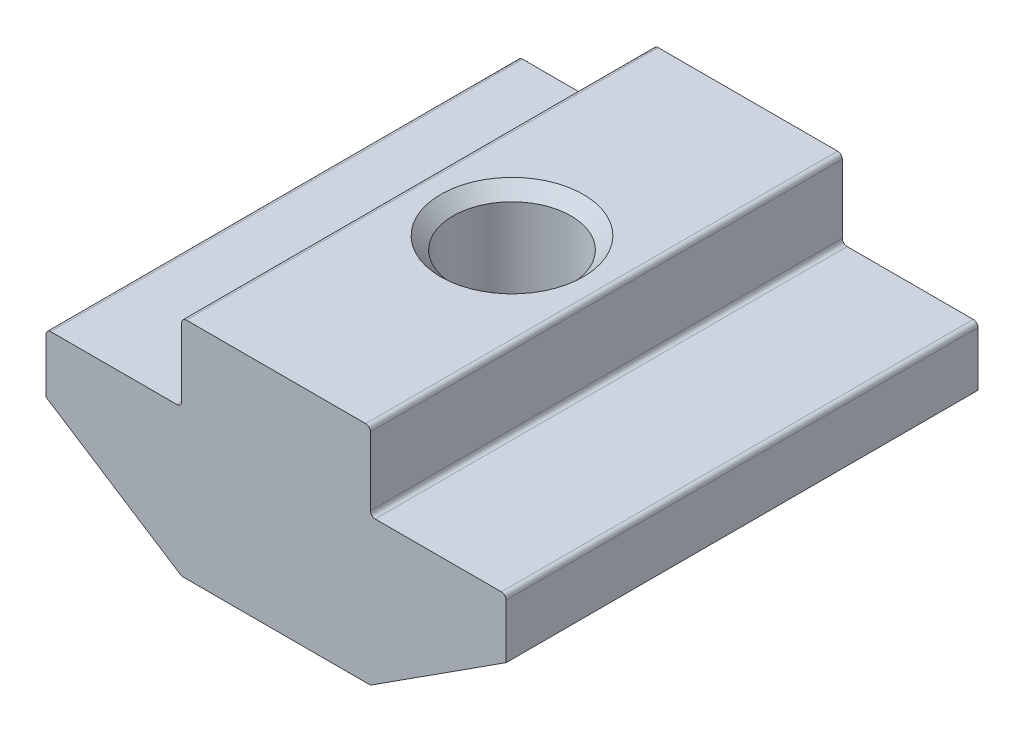
from build123d import *

# Parameters (mm, degrees)
EXTRUDE_1_DEPTH = 10
FILLET_1_R      = 0.2


with BuildPart() as part:
    # Эскиз1 → Бобышка-Вытянуть1 (new body, symmetric)
    with BuildSketch(Plane.XY):
        Polygon((4, 0), (-4, 0), (-4, -3.3), (-9.75, -3.3), (-9.75, -5.8), (-4, -9.5), (4, -9.5), (9.75, -5.8), (9.75, -3.3), (4, -3.3), align=None)
    extrude(amount=EXTRUDE_1_DEPTH, both=True)

    # Эскиз4 → Отверстие обработанное метчиком M63 (revolve, cut)
    with BuildSketch(Plane(origin=(0, 0, 0), x_dir=(0, 0, 1), z_dir=(1, 0, 0))):
        Polygon((0, 0), (0, 9.5), (3.025, 9.5), (2.5, 8.975), (2.5, 0.525), (3.025, 0), align=None)
    revolve(axis=Axis((0, 6.35, 0), (0, -1, 0)), mode=Mode.SUBTRACT)

    # Скругление1
    fillet_1_edges = [part.edges().sort_by_distance(p)[0] for p in [
        (-4, 0, 0),
        (4, 0, 0),
        (4, -3.3, 0),
        (9.75, -3.3, 0),
        (4, -9.5, 0),
        (-4, -9.5, 0),
        (-9.75, -3.3, 0),
        (-4, -3.3, 0),
    ]]
    fillet(fillet_1_edges, radius=FILLET_1_R)


solid = part.part
